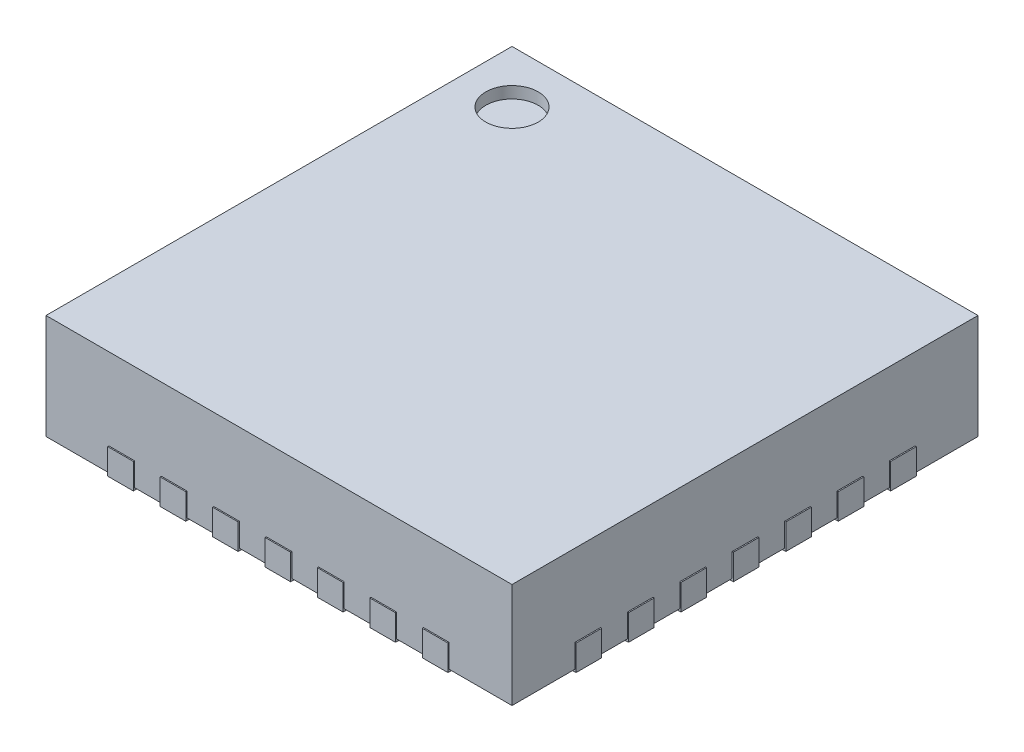
from build123d import *

# Parameters (mm, degrees)
SKETCH2_W                   = 4
SKETCH2_H                   = 4
BOSS_EXTRUDE1_DEPTH         = 0.9
SKETCH3_W                   = 2.4
SKETCH3_H                   = 2.4
BOSS_EXTRUDE2_DEPTH         = 0.02
BOSS_EXTRUDE2_DEPTH_BACK    = 0.2
SKETCH3_W_2                 = 0.4
SKETCH3_H_2                 = 0.22
BOSS_EXTRUDE2_2_DEPTH       = 0.02
BOSS_EXTRUDE2_2_DEPTH_BACK  = 0.2
BOSS_EXTRUDE2_3_DEPTH       = 0.02
BOSS_EXTRUDE2_3_DEPTH_BACK  = 0.2
BOSS_EXTRUDE2_4_DEPTH       = 0.02
BOSS_EXTRUDE2_4_DEPTH_BACK  = 0.2
BOSS_EXTRUDE2_5_DEPTH       = 0.02
BOSS_EXTRUDE2_5_DEPTH_BACK  = 0.2
BOSS_EXTRUDE2_6_DEPTH       = 0.02
BOSS_EXTRUDE2_6_DEPTH_BACK  = 0.2
BOSS_EXTRUDE2_7_DEPTH       = 0.02
BOSS_EXTRUDE2_7_DEPTH_BACK  = 0.2
BOSS_EXTRUDE2_8_DEPTH       = 0.02
BOSS_EXTRUDE2_8_DEPTH_BACK  = 0.2
SKETCH3_W_3                 = 0.22
SKETCH3_H_3                 = 0.4
BOSS_EXTRUDE2_9_DEPTH       = 0.02
BOSS_EXTRUDE2_9_DEPTH_BACK  = 0.2
BOSS_EXTRUDE2_10_DEPTH      = 0.02
BOSS_EXTRUDE2_10_DEPTH_BACK = 0.2
BOSS_EXTRUDE2_11_DEPTH      = 0.02
BOSS_EXTRUDE2_11_DEPTH_BACK = 0.2
BOSS_EXTRUDE2_12_DEPTH      = 0.02
BOSS_EXTRUDE2_12_DEPTH_BACK = 0.2
BOSS_EXTRUDE2_13_DEPTH      = 0.02
BOSS_EXTRUDE2_13_DEPTH_BACK = 0.2
BOSS_EXTRUDE2_14_DEPTH      = 0.02
BOSS_EXTRUDE2_14_DEPTH_BACK = 0.2
BOSS_EXTRUDE2_15_DEPTH      = 0.02
BOSS_EXTRUDE2_15_DEPTH_BACK = 0.2
BOSS_EXTRUDE2_16_DEPTH      = 0.02
BOSS_EXTRUDE2_16_DEPTH_BACK = 0.2
BOSS_EXTRUDE2_17_DEPTH      = 0.02
BOSS_EXTRUDE2_17_DEPTH_BACK = 0.2
BOSS_EXTRUDE2_18_DEPTH      = 0.02
BOSS_EXTRUDE2_18_DEPTH_BACK = 0.2
BOSS_EXTRUDE2_19_DEPTH      = 0.02
BOSS_EXTRUDE2_19_DEPTH_BACK = 0.2
BOSS_EXTRUDE2_20_DEPTH      = 0.02
BOSS_EXTRUDE2_20_DEPTH_BACK = 0.2
BOSS_EXTRUDE2_21_DEPTH      = 0.02
BOSS_EXTRUDE2_21_DEPTH_BACK = 0.2
BOSS_EXTRUDE2_22_DEPTH      = 0.02
BOSS_EXTRUDE2_22_DEPTH_BACK = 0.2
BOSS_EXTRUDE2_23_DEPTH      = 0.02
BOSS_EXTRUDE2_23_DEPTH_BACK = 0.2
BOSS_EXTRUDE2_24_DEPTH      = 0.02
BOSS_EXTRUDE2_24_DEPTH_BACK = 0.2
BOSS_EXTRUDE2_25_DEPTH      = 0.02
BOSS_EXTRUDE2_25_DEPTH_BACK = 0.2
BOSS_EXTRUDE2_26_DEPTH      = 0.02
BOSS_EXTRUDE2_26_DEPTH_BACK = 0.2
BOSS_EXTRUDE2_27_DEPTH      = 0.02
BOSS_EXTRUDE2_27_DEPTH_BACK = 0.2
BOSS_EXTRUDE2_28_DEPTH      = 0.02
BOSS_EXTRUDE2_28_DEPTH_BACK = 0.2
BOSS_EXTRUDE2_29_DEPTH      = 0.02
BOSS_EXTRUDE2_29_DEPTH_BACK = 0.2
SKETCH4_R                   = 0.225
CUT_EXTRUDE1_DEPTH          = 0.1


with BuildPart() as part:
    # Sketch2 → Boss-Extrude1 (new body)
    with BuildSketch(Plane(origin=(0, 0, 0), x_dir=(1, 0, 0), z_dir=(0, 1, 0))):
        Rectangle(SKETCH2_W, SKETCH2_H)
    extrude(amount=BOSS_EXTRUDE1_DEPTH)

    # Sketch4 → Cut-Extrude1 (cut)
    with BuildSketch(Plane(origin=(0, 0.9, 0), x_dir=(1, 0, 0), z_dir=(0, 1, 0))):
        with Locations((-1.55, 1.55)):
            Circle(SKETCH4_R)
    extrude(amount=-CUT_EXTRUDE1_DEPTH, mode=Mode.SUBTRACT)


with BuildPart() as body_2:
    # Sketch3 → Boss-Extrude2 (new body, two sides)
    with BuildSketch(Plane.XZ) as boss_extrude2_sk:
        Rectangle(SKETCH3_W, SKETCH3_H)
    extrude(amount=BOSS_EXTRUDE2_DEPTH)
    extrude(boss_extrude2_sk.sketch, amount=-BOSS_EXTRUDE2_DEPTH_BACK)


with BuildPart() as body_3:
    # Sketch3 → Boss-Extrude2 2 (new body, two sides)
    with BuildSketch(Plane.XZ) as boss_extrude2_2_sk:
        with Locations((-1.81, 0.45)):
            Rectangle(SKETCH3_W_2, SKETCH3_H_2)
    extrude(amount=BOSS_EXTRUDE2_2_DEPTH)
    extrude(boss_extrude2_2_sk.sketch, amount=-BOSS_EXTRUDE2_2_DEPTH_BACK)


with BuildPart() as body_4:
    # Sketch3 → Boss-Extrude2 3 (new body, two sides)
    with BuildSketch(Plane.XZ) as boss_extrude2_3_sk:
        with Locations((-1.81, 0)):
            Rectangle(SKETCH3_W_2, SKETCH3_H_2)
    extrude(amount=BOSS_EXTRUDE2_3_DEPTH)
    extrude(boss_extrude2_3_sk.sketch, amount=-BOSS_EXTRUDE2_3_DEPTH_BACK)


with BuildPart() as body_5:
    # Sketch3 → Boss-Extrude2 4 (new body, two sides)
    with BuildSketch(Plane.XZ) as boss_extrude2_4_sk:
        with Locations((-1.81, 0.9)):
            Rectangle(SKETCH3_W_2, SKETCH3_H_2)
    extrude(amount=BOSS_EXTRUDE2_4_DEPTH)
    extrude(boss_extrude2_4_sk.sketch, amount=-BOSS_EXTRUDE2_4_DEPTH_BACK)


with BuildPart() as body_6:
    # Sketch3 → Boss-Extrude2 5 (new body, two sides)
    with BuildSketch(Plane.XZ) as boss_extrude2_5_sk:
        with Locations((-1.81, 1.35)):
            Rectangle(SKETCH3_W_2, SKETCH3_H_2)
    extrude(amount=BOSS_EXTRUDE2_5_DEPTH)
    extrude(boss_extrude2_5_sk.sketch, amount=-BOSS_EXTRUDE2_5_DEPTH_BACK)


with BuildPart() as body_7:
    # Sketch3 → Boss-Extrude2 6 (new body, two sides)
    with BuildSketch(Plane.XZ) as boss_extrude2_6_sk:
        with Locations((-1.81, -0.45)):
            Rectangle(SKETCH3_W_2, SKETCH3_H_2)
    extrude(amount=BOSS_EXTRUDE2_6_DEPTH)
    extrude(boss_extrude2_6_sk.sketch, amount=-BOSS_EXTRUDE2_6_DEPTH_BACK)


with BuildPart() as body_8:
    # Sketch3 → Boss-Extrude2 7 (new body, two sides)
    with BuildSketch(Plane.XZ) as boss_extrude2_7_sk:
        with Locations((-1.81, -0.9)):
            Rectangle(SKETCH3_W_2, SKETCH3_H_2)
    extrude(amount=BOSS_EXTRUDE2_7_DEPTH)
    extrude(boss_extrude2_7_sk.sketch, amount=-BOSS_EXTRUDE2_7_DEPTH_BACK)


with BuildPart() as body_9:
    # Sketch3 → Boss-Extrude2 8 (new body, two sides)
    with BuildSketch(Plane.XZ) as boss_extrude2_8_sk:
        with Locations((-1.81, -1.35)):
            Rectangle(SKETCH3_W_2, SKETCH3_H_2)
    extrude(amount=BOSS_EXTRUDE2_8_DEPTH)
    extrude(boss_extrude2_8_sk.sketch, amount=-BOSS_EXTRUDE2_8_DEPTH_BACK)


with BuildPart() as body_10:
    # Sketch3 → Boss-Extrude2 9 (new body, two sides)
    with BuildSketch(Plane.XZ) as boss_extrude2_9_sk:
        with Locations((0.45, 1.81)):
            Rectangle(SKETCH3_W_3, SKETCH3_H_3)
    extrude(amount=BOSS_EXTRUDE2_9_DEPTH)
    extrude(boss_extrude2_9_sk.sketch, amount=-BOSS_EXTRUDE2_9_DEPTH_BACK)


with BuildPart() as body_11:
    # Sketch3 → Boss-Extrude2 10 (new body, two sides)
    with BuildSketch(Plane.XZ) as boss_extrude2_10_sk:
        with Locations((0, 1.81)):
            Rectangle(SKETCH3_W_3, SKETCH3_H_3)
    extrude(amount=BOSS_EXTRUDE2_10_DEPTH)
    extrude(boss_extrude2_10_sk.sketch, amount=-BOSS_EXTRUDE2_10_DEPTH_BACK)


with BuildPart() as body_12:
    # Sketch3 → Boss-Extrude2 11 (new body, two sides)
    with BuildSketch(Plane.XZ) as boss_extrude2_11_sk:
        with Locations((0.9, 1.81)):
            Rectangle(SKETCH3_W_3, SKETCH3_H_3)
    extrude(amount=BOSS_EXTRUDE2_11_DEPTH)
    extrude(boss_extrude2_11_sk.sketch, amount=-BOSS_EXTRUDE2_11_DEPTH_BACK)


with BuildPart() as body_13:
    # Sketch3 → Boss-Extrude2 12 (new body, two sides)
    with BuildSketch(Plane.XZ) as boss_extrude2_12_sk:
        with Locations((1.35, 1.81)):
            Rectangle(SKETCH3_W_3, SKETCH3_H_3)
    extrude(amount=BOSS_EXTRUDE2_12_DEPTH)
    extrude(boss_extrude2_12_sk.sketch, amount=-BOSS_EXTRUDE2_12_DEPTH_BACK)


with BuildPart() as body_14:
    # Sketch3 → Boss-Extrude2 13 (new body, two sides)
    with BuildSketch(Plane.XZ) as boss_extrude2_13_sk:
        with Locations((-0.45, 1.81)):
            Rectangle(SKETCH3_W_3, SKETCH3_H_3)
    extrude(amount=BOSS_EXTRUDE2_13_DEPTH)
    extrude(boss_extrude2_13_sk.sketch, amount=-BOSS_EXTRUDE2_13_DEPTH_BACK)


with BuildPart() as body_15:
    # Sketch3 → Boss-Extrude2 14 (new body, two sides)
    with BuildSketch(Plane.XZ) as boss_extrude2_14_sk:
        with Locations((-0.9, 1.81)):
            Rectangle(SKETCH3_W_3, SKETCH3_H_3)
    extrude(amount=BOSS_EXTRUDE2_14_DEPTH)
    extrude(boss_extrude2_14_sk.sketch, amount=-BOSS_EXTRUDE2_14_DEPTH_BACK)


with BuildPart() as body_16:
    # Sketch3 → Boss-Extrude2 15 (new body, two sides)
    with BuildSketch(Plane.XZ) as boss_extrude2_15_sk:
        with Locations((-1.35, 1.81)):
            Rectangle(SKETCH3_W_3, SKETCH3_H_3)
    extrude(amount=BOSS_EXTRUDE2_15_DEPTH)
    extrude(boss_extrude2_15_sk.sketch, amount=-BOSS_EXTRUDE2_15_DEPTH_BACK)


with BuildPart() as body_17:
    # Sketch3 → Boss-Extrude2 16 (new body, two sides)
    with BuildSketch(Plane.XZ) as boss_extrude2_16_sk:
        with Locations((1.81, -0.45)):
            Rectangle(SKETCH3_W_2, SKETCH3_H_2)
    extrude(amount=BOSS_EXTRUDE2_16_DEPTH)
    extrude(boss_extrude2_16_sk.sketch, amount=-BOSS_EXTRUDE2_16_DEPTH_BACK)


with BuildPart() as body_18:
    # Sketch3 → Boss-Extrude2 17 (new body, two sides)
    with BuildSketch(Plane.XZ) as boss_extrude2_17_sk:
        with Locations((1.81, 0)):
            Rectangle(SKETCH3_W_2, SKETCH3_H_2)
    extrude(amount=BOSS_EXTRUDE2_17_DEPTH)
    extrude(boss_extrude2_17_sk.sketch, amount=-BOSS_EXTRUDE2_17_DEPTH_BACK)


with BuildPart() as body_19:
    # Sketch3 → Boss-Extrude2 18 (new body, two sides)
    with BuildSketch(Plane.XZ) as boss_extrude2_18_sk:
        with Locations((1.81, -0.9)):
            Rectangle(SKETCH3_W_2, SKETCH3_H_2)
    extrude(amount=BOSS_EXTRUDE2_18_DEPTH)
    extrude(boss_extrude2_18_sk.sketch, amount=-BOSS_EXTRUDE2_18_DEPTH_BACK)


with BuildPart() as body_20:
    # Sketch3 → Boss-Extrude2 19 (new body, two sides)
    with BuildSketch(Plane.XZ) as boss_extrude2_19_sk:
        with Locations((1.81, -1.35)):
            Rectangle(SKETCH3_W_2, SKETCH3_H_2)
    extrude(amount=BOSS_EXTRUDE2_19_DEPTH)
    extrude(boss_extrude2_19_sk.sketch, amount=-BOSS_EXTRUDE2_19_DEPTH_BACK)


with BuildPart() as body_21:
    # Sketch3 → Boss-Extrude2 20 (new body, two sides)
    with BuildSketch(Plane.XZ) as boss_extrude2_20_sk:
        with Locations((1.81, 0.45)):
            Rectangle(SKETCH3_W_2, SKETCH3_H_2)
    extrude(amount=BOSS_EXTRUDE2_20_DEPTH)
    extrude(boss_extrude2_20_sk.sketch, amount=-BOSS_EXTRUDE2_20_DEPTH_BACK)


with BuildPart() as body_22:
    # Sketch3 → Boss-Extrude2 21 (new body, two sides)
    with BuildSketch(Plane.XZ) as boss_extrude2_21_sk:
        with Locations((1.81, 0.9)):
            Rectangle(SKETCH3_W_2, SKETCH3_H_2)
    extrude(amount=BOSS_EXTRUDE2_21_DEPTH)
    extrude(boss_extrude2_21_sk.sketch, amount=-BOSS_EXTRUDE2_21_DEPTH_BACK)


with BuildPart() as body_23:
    # Sketch3 → Boss-Extrude2 22 (new body, two sides)
    with BuildSketch(Plane.XZ) as boss_extrude2_22_sk:
        with Locations((1.81, 1.35)):
            Rectangle(SKETCH3_W_2, SKETCH3_H_2)
    extrude(amount=BOSS_EXTRUDE2_22_DEPTH)
    extrude(boss_extrude2_22_sk.sketch, amount=-BOSS_EXTRUDE2_22_DEPTH_BACK)


with BuildPart() as body_24:
    # Sketch3 → Boss-Extrude2 23 (new body, two sides)
    with BuildSketch(Plane.XZ) as boss_extrude2_23_sk:
        with Locations((-0.45, -1.81)):
            Rectangle(SKETCH3_W_3, SKETCH3_H_3)
    extrude(amount=BOSS_EXTRUDE2_23_DEPTH)
    extrude(boss_extrude2_23_sk.sketch, amount=-BOSS_EXTRUDE2_23_DEPTH_BACK)


with BuildPart() as body_25:
    # Sketch3 → Boss-Extrude2 24 (new body, two sides)
    with BuildSketch(Plane.XZ) as boss_extrude2_24_sk:
        with Locations((0, -1.81)):
            Rectangle(SKETCH3_W_3, SKETCH3_H_3)
    extrude(amount=BOSS_EXTRUDE2_24_DEPTH)
    extrude(boss_extrude2_24_sk.sketch, amount=-BOSS_EXTRUDE2_24_DEPTH_BACK)


with BuildPart() as body_26:
    # Sketch3 → Boss-Extrude2 25 (new body, two sides)
    with BuildSketch(Plane.XZ) as boss_extrude2_25_sk:
        with Locations((-0.9, -1.81)):
            Rectangle(SKETCH3_W_3, SKETCH3_H_3)
    extrude(amount=BOSS_EXTRUDE2_25_DEPTH)
    extrude(boss_extrude2_25_sk.sketch, amount=-BOSS_EXTRUDE2_25_DEPTH_BACK)


with BuildPart() as body_27:
    # Sketch3 → Boss-Extrude2 26 (new body, two sides)
    with BuildSketch(Plane.XZ) as boss_extrude2_26_sk:
        with Locations((-1.35, -1.81)):
            Rectangle(SKETCH3_W_3, SKETCH3_H_3)
    extrude(amount=BOSS_EXTRUDE2_26_DEPTH)
    extrude(boss_extrude2_26_sk.sketch, amount=-BOSS_EXTRUDE2_26_DEPTH_BACK)


with BuildPart() as body_28:
    # Sketch3 → Boss-Extrude2 27 (new body, two sides)
    with BuildSketch(Plane.XZ) as boss_extrude2_27_sk:
        with Locations((0.45, -1.81)):
            Rectangle(SKETCH3_W_3, SKETCH3_H_3)
    extrude(amount=BOSS_EXTRUDE2_27_DEPTH)
    extrude(boss_extrude2_27_sk.sketch, amount=-BOSS_EXTRUDE2_27_DEPTH_BACK)


with BuildPart() as body_29:
    # Sketch3 → Boss-Extrude2 28 (new body, two sides)
    with BuildSketch(Plane.XZ) as boss_extrude2_28_sk:
        with Locations((0.9, -1.81)):
            Rectangle(SKETCH3_W_3, SKETCH3_H_3)
    extrude(amount=BOSS_EXTRUDE2_28_DEPTH)
    extrude(boss_extrude2_28_sk.sketch, amount=-BOSS_EXTRUDE2_28_DEPTH_BACK)


with BuildPart() as body_30:
    # Sketch3 → Boss-Extrude2 29 (new body, two sides)
    with BuildSketch(Plane.XZ) as boss_extrude2_29_sk:
        with Locations((1.35, -1.81)):
            Rectangle(SKETCH3_W_3, SKETCH3_H_3)
    extrude(amount=BOSS_EXTRUDE2_29_DEPTH)
    extrude(boss_extrude2_29_sk.sketch, amount=-BOSS_EXTRUDE2_29_DEPTH_BACK)


solid = Compound([part.part, body_2.part, body_3.part, body_4.part, body_5.part, body_6.part, body_7.part, body_8.part, body_9.part, body_10.part, body_11.part, body_12.part, body_13.part, body_14.part, body_15.part, body_16.part, body_17.part, body_18.part, body_19.part, body_20.part, body_21.part, body_22.part, body_23.part, body_24.part, body_25.part, body_26.part, body_27.part, body_28.part, body_29.part, body_30.part])
